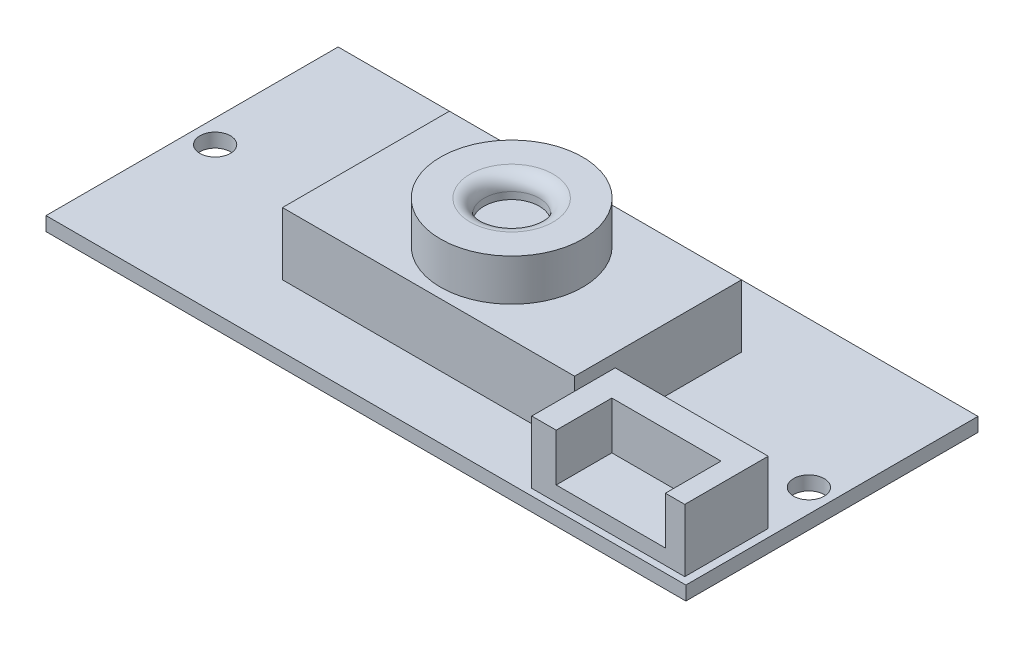
from build123d import *

# Parameters (mm, degrees)
SKETCH1_W           = 46
SKETCH1_H           = 21
BOSS_EXTRUDE1_DEPTH = 1
SKETCH2_W           = 21
SKETCH2_H           = 12
SKETCH2_W_2         = 11
SKETCH2_H_2         = 6
BOSS_EXTRUDE2_DEPTH = 4.5
SKETCH3_W           = 7.849871035
SKETCH3_H           = 3.412332869
CUT_EXTRUDE1_DEPTH  = 4
SKETCH4_R           = 5.109251927
BOSS_EXTRUDE3_DEPTH = 3
SKETCH5_R           = 1.986847175
CUT_EXTRUDE2_DEPTH  = 1.5
FILLET1_R           = 1
SKETCH6_R           = 1.1
CUT_EXTRUDE3_DEPTH  = 1.5


with BuildPart() as part:
    # Sketch1 → Boss-Extrude1 (new body)
    with BuildSketch(Plane(origin=(0, 0, 0), x_dir=(1, 0, 0), z_dir=(0, 1, 0))):
        with Locations((23, -10.5)):
            Rectangle(SKETCH1_W, SKETCH1_H)
    extrude(amount=BOSS_EXTRUDE1_DEPTH)

    # Sketch2 → Boss-Extrude2 (add)
    with BuildSketch(Plane(origin=(0, 1, 0), x_dir=(1, 0, 0), z_dir=(0, 1, 0))):
        with Locations((23, -10.5)):
            Rectangle(SKETCH2_W, SKETCH2_H)
        with Locations((39.939580859, -17.520481264)):
            Rectangle(SKETCH2_W_2, SKETCH2_H_2)
    extrude(amount=BOSS_EXTRUDE2_DEPTH)

    # Sketch3 → Cut-Extrude1 (cut)
    with BuildSketch(Plane.XY.offset(20.520481264)):
        with Locations((40.122531197, 3.793833565)):
            Rectangle(SKETCH3_W, SKETCH3_H)
    extrude(amount=-CUT_EXTRUDE1_DEPTH, mode=Mode.SUBTRACT)

    # Sketch4 → Boss-Extrude3 (add)
    with BuildSketch(Plane(origin=(0, 5.5, 0), x_dir=(1, 0, 0), z_dir=(0, 1, 0))):
        with Locations((23.147185082, -10.671715929)):
            Circle(SKETCH4_R)
    extrude(amount=BOSS_EXTRUDE3_DEPTH)

    # Sketch5 → Cut-Extrude2 (cut)
    with BuildSketch(Plane(origin=(0, 8.5, 0), x_dir=(1, 0, 0), z_dir=(0, 1, 0))):
        with Locations((23.147185082, -10.671715929)):
            Circle(SKETCH5_R)
    extrude(amount=-CUT_EXTRUDE2_DEPTH, mode=Mode.SUBTRACT)

    # Fillet1
    fillet1_edges = [part.edges().sort_by_distance(p)[0] for p in [
        (21.160337907, 8.5, 10.671715929),
    ]]
    fillet(fillet1_edges, radius=FILLET1_R)

    # Sketch6 → Cut-Extrude3 (cut)
    with BuildSketch(Plane(origin=(0, 1, 0), x_dir=(1, 0, 0), z_dir=(0, 1, 0))):
        with Locations((1.658163122, -10.5)):
            Circle(SKETCH6_R)
        with Locations((44.341836878, -10.5)):
            Circle(SKETCH6_R)
    extrude(amount=-CUT_EXTRUDE3_DEPTH, mode=Mode.SUBTRACT)


solid = part.part
